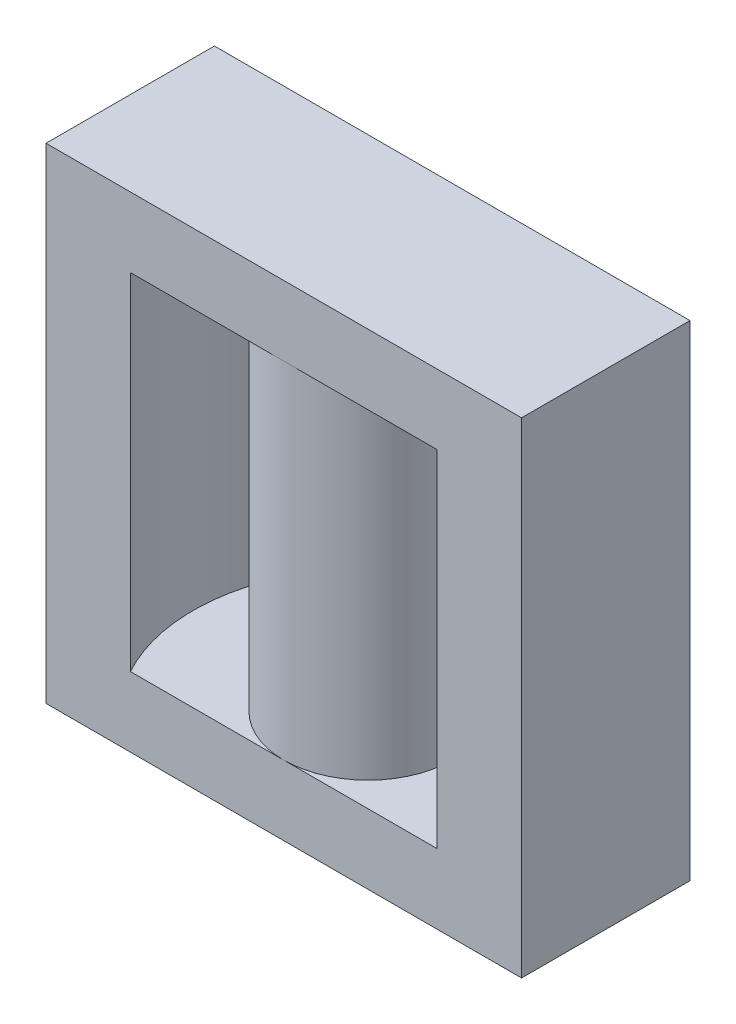
from build123d import *

# Parameters (mm, degrees)
BOSS_EXTRUDE1_DEPTH   = 55.6
SKETCH1_R             = 9.65
BOSS_EXTRUDE1_2_DEPTH = 55.6
BOSS_EXTRUDE1_3_DEPTH = 55.6
SKETCH2_W             = 54.5
SKETCH2_H             = 19.3
BOSS_EXTRUDE2_DEPTH   = 8
SKETCH3_W             = 54.5
SKETCH3_H             = 19.3
BOSS_EXTRUDE3_DEPTH   = 8


with BuildPart() as part:
    # Sketch1 → Boss-Extrude1 (new body)
    with BuildSketch(Plane(origin=(0, 0, 0), x_dir=(1, 0, 0), z_dir=(0, 1, 0))):
        with BuildLine():
            Line((-17.574982219, 9.65), (-27.25, 9.65))
            Line((-27.25, 9.65), (-27.25, -9.65))
            Line((-27.25, -9.65), (-17.574982219, -9.65))
            ThreePointArc((-17.574982219, -9.65), (-20.05, 0), (-17.574982219, 9.65))
        make_face()
    extrude(amount=BOSS_EXTRUDE1_DEPTH)



with BuildPart() as body_2:
    # Sketch1 → Boss-Extrude1 2 (new body)
    with BuildSketch(Plane(origin=(0, 0, 0), x_dir=(1, 0, 0), z_dir=(0, 1, 0))):
        Circle(SKETCH1_R)
    extrude(amount=BOSS_EXTRUDE1_2_DEPTH)


with BuildPart() as body_3:
    # Sketch1 → Boss-Extrude1 3 (new body)
    with BuildSketch(Plane(origin=(0, 0, 0), x_dir=(1, 0, 0), z_dir=(0, 1, 0))):
        with BuildLine():
            Line((27.25, 9.65), (17.574982219, 9.65))
            ThreePointArc((17.574982219, 9.65), (19.421391473, 4.981169868), (20.05, 0))
            ThreePointArc((20.05, 0), (19.421391473, -4.981169868), (17.574982219, -9.65))
            Line((17.574982219, -9.65), (27.25, -9.65))
            Line((27.25, -9.65), (27.25, 9.65))
        make_face()
    extrude(amount=BOSS_EXTRUDE1_3_DEPTH)


with BuildPart() as part_1:
    add(part.part)

    add(body_2.part)  # Boss-Extrude2 merges body 2

    add(body_3.part)  # Boss-Extrude2 merges body 3
    # Sketch2 → Boss-Extrude2 (add)
    with BuildSketch(Plane(origin=(0, 55.6, 0), x_dir=(1, 0, 0), z_dir=(0, 1, 0))):
        Rectangle(SKETCH2_W, SKETCH2_H)
    extrude(amount=-BOSS_EXTRUDE2_DEPTH)

    # Sketch3 → Boss-Extrude3 (add)
    with BuildSketch(Plane.XZ):
        Rectangle(SKETCH3_W, SKETCH3_H)
    extrude(amount=-BOSS_EXTRUDE3_DEPTH)


solid = part_1.part
